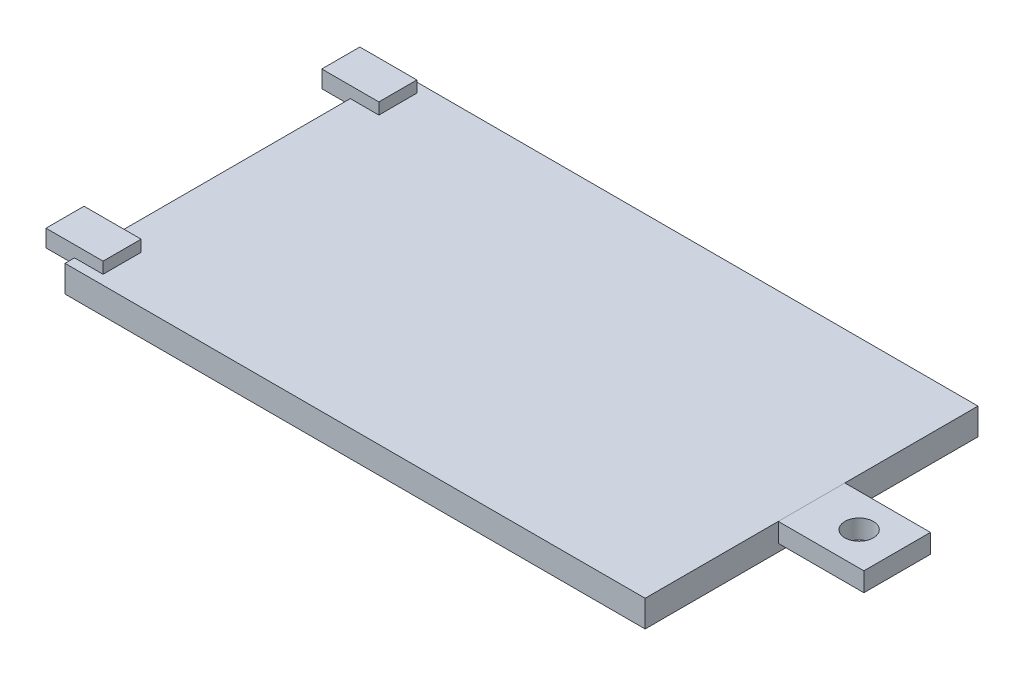
from build123d import *

# Parameters (mm, degrees)
SKETCH_1_W      = 61
SKETCH_1_H      = 35
EXTRUDE_1_DEPTH = 2.8
SKETCH_2_W      = 9
SKETCH_2_H      = 7
SKETCH_2_R      = 1.5
EXTRUDE_2_DEPTH = 2
SKETCH_3_W      = 4
SKETCH_3_H      = 1.8
EXTRUDE_3_DEPTH = 3


with BuildPart() as part:
    # 草图1 → 凸台-拉伸1 (new body)
    with BuildSketch(Plane(origin=(0, 0, 0), x_dir=(1, 0, 0), z_dir=(0, 1, 0))):
        with Locations((30.5, 17.5)):
            Rectangle(SKETCH_1_W, SKETCH_1_H)
    extrude(amount=EXTRUDE_1_DEPTH)

    # 草图3 → 凸台-拉伸3 (add, symmetric)
    with BuildSketch(Plane.ZY):
        with Locations((-3, 3.1)):
            Rectangle(SKETCH_3_W, SKETCH_3_H)
        with Locations((-32, 3.1)):
            Rectangle(SKETCH_3_W, SKETCH_3_H)
    extrude(amount=EXTRUDE_3_DEPTH, both=True)


with BuildPart() as body_2:
    # 草图2 → 凸台-拉伸2 (new body)
    with BuildSketch(Plane.XZ.offset(-2.8)):
        with Locations((65.5, -17.5)):
            Rectangle(SKETCH_2_W, SKETCH_2_H)
        with Locations((66, -17.5)):
            Circle(SKETCH_2_R, mode=Mode.SUBTRACT)
    extrude(amount=EXTRUDE_2_DEPTH)


solid = Compound([part.part, body_2.part])
